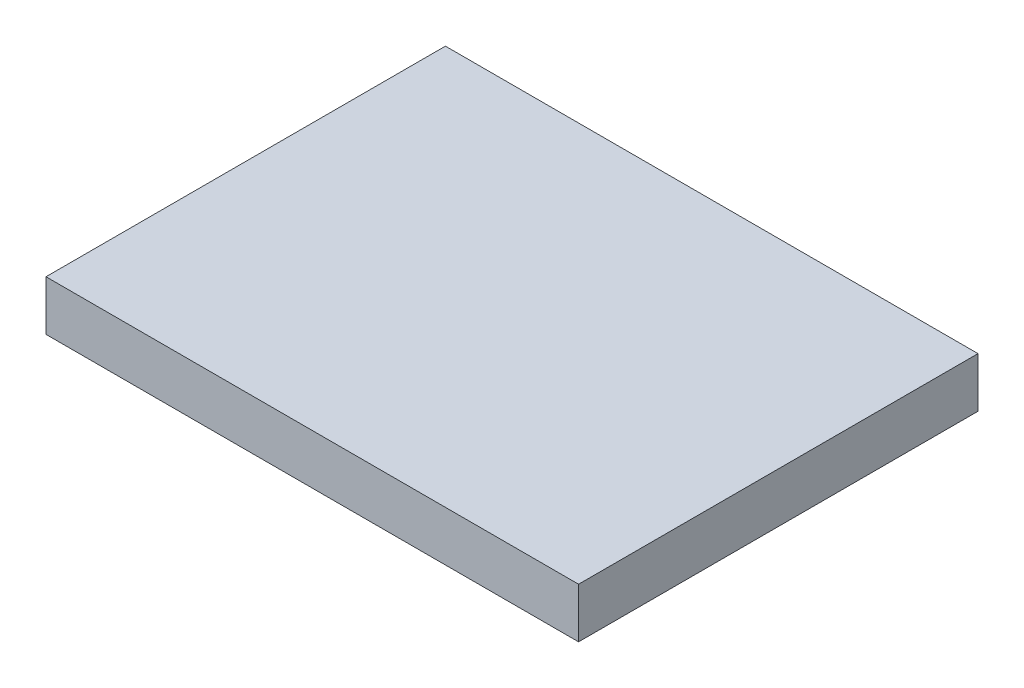
from build123d import *

# Parameters (mm, degrees)
SKETCH1_W           = 50.8
SKETCH1_H           = 38.1
BOSS_EXTRUDE1_DEPTH = 4.7625


with BuildPart() as part:
    # Sketch1 → Boss-Extrude1 (new body)
    with BuildSketch(Plane(origin=(0, 0, 0), x_dir=(1, 0, 0), z_dir=(0, 1, 0))):
        Rectangle(SKETCH1_W, SKETCH1_H)
    extrude(amount=BOSS_EXTRUDE1_DEPTH)


solid = part.part
